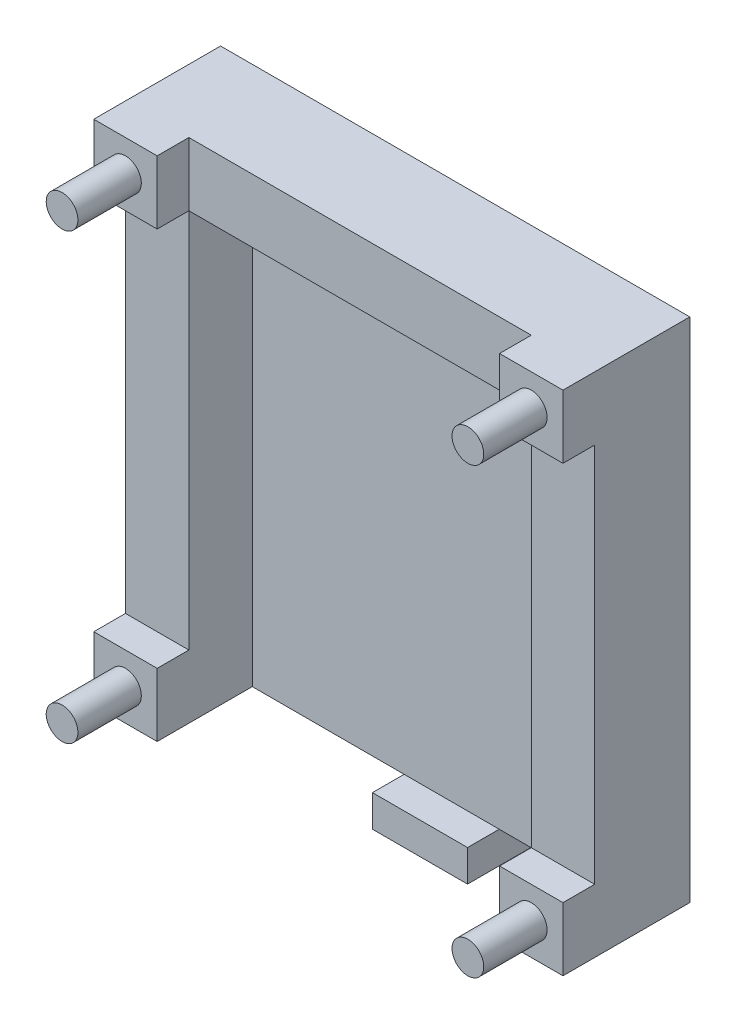
from build123d import *

# Parameters (mm, degrees)
CROQUIS1_W               = 54
CROQUIS1_H               = 70
SALIENTE_EXTRUIR1_DEPTH  = 5
CROQUIS4_W               = 54
CROQUIS4_H               = 10
SALIENTE_EXTRUIR5_DEPTH  = 15
CROQUIS5_W               = 10
CROQUIS5_H               = 10
SALIENTE_EXTRUIR6_DEPTH  = 20
CROQUIS6_W               = 15
CROQUIS6_H               = 5
SALIENTE_EXTRUIR7_DEPTH  = 10
CROQUIS8_W               = 10
CROQUIS8_H               = 60
SALIENTE_EXTRUIR9_DEPTH  = 15
CROQUIS9_R               = 2.5
SALIENTE_EXTRUIR10_DEPTH = 10


with BuildPart() as part:
    # Croquis1 → Saliente-Extruir1 (new body)
    with BuildSketch(Plane.XY):
        with Locations((28.400543811, 1.50863747)):
            Rectangle(CROQUIS1_W, CROQUIS1_H)
    extrude(amount=SALIENTE_EXTRUIR1_DEPTH)

    # Croquis4 → Saliente-Extruir5 (add)
    with BuildSketch(Plane(origin=(0, 0, 0), x_dir=(-1, 0, 0), z_dir=(0, 0, -1))):
        with Locations((-28.400543811, 41.50863747)):
            Rectangle(CROQUIS4_W, CROQUIS4_H)
    extrude(amount=-SALIENTE_EXTRUIR5_DEPTH)

    # Croquis5 → Saliente-Extruir6 (add)
    with BuildSketch(Plane(origin=(0, 0, 0), x_dir=(-1, 0, 0), z_dir=(0, 0, -1))):
        with Locations((-60.400543811, 41.50863747)):
            Rectangle(CROQUIS5_W, CROQUIS5_H)
        with Locations((-60.400543811, -28.49136253)):
            Rectangle(CROQUIS5_W, CROQUIS5_H)
        with Locations((3.599456189, -28.49136253)):
            Rectangle(CROQUIS5_W, CROQUIS5_H)
        with Locations((3.599456189, 41.50863747)):
            Rectangle(CROQUIS5_W, CROQUIS5_H)
    extrude(amount=-SALIENTE_EXTRUIR6_DEPTH)

    # Croquis8 → Saliente-Extruir9 (add)
    with BuildSketch(Plane(origin=(0, 0, 0), x_dir=(-1, 0, 0), z_dir=(0, 0, -1))):
        with Locations((-60.400543811, 6.50863747)):
            Rectangle(CROQUIS8_W, CROQUIS8_H)
        with Locations((3.599456189, 6.50863747)):
            Rectangle(CROQUIS8_W, CROQUIS8_H)
    extrude(amount=-SALIENTE_EXTRUIR9_DEPTH)

    # Croquis9 → Saliente-Extruir10 (add)
    with BuildSketch(Plane.XY.offset(20)):
        with BuildLine():
            ThreePointArc((-1.099456189, 41.50863747), (-3.599456189, 44.00863747), (-6.099456189, 41.50863747))
            Line((-6.099456189, 41.50863747), (-1.099456189, 41.50863747))
        make_face()
        with BuildLine():
            Line((-1.099456189, 41.50863747), (-6.099456189, 41.50863747))
            ThreePointArc((-6.099456189, 41.50863747), (-3.599456189, 39.00863747), (-1.099456189, 41.50863747))
        make_face()
        with Locations((60.400543811, 41.50863747)):
            Circle(CROQUIS9_R)
        with Locations((60.400543811, -28.49136253)):
            Circle(CROQUIS9_R)
        with Locations((-3.599456189, -28.49136253)):
            Circle(CROQUIS9_R)
    extrude(amount=SALIENTE_EXTRUIR10_DEPTH)


with BuildPart() as body_2:
    # Croquis6 → Saliente-Extruir7 (new body)
    with BuildSketch(Plane(origin=(0, 0, 0), x_dir=(-1, 0, 0), z_dir=(0, 0, -1))):
        with Locations((-32.848967284, -35.99136253)):
            Rectangle(CROQUIS6_W, CROQUIS6_H)
    extrude(amount=-SALIENTE_EXTRUIR7_DEPTH)


solid = Compound([part.part, body_2.part])
